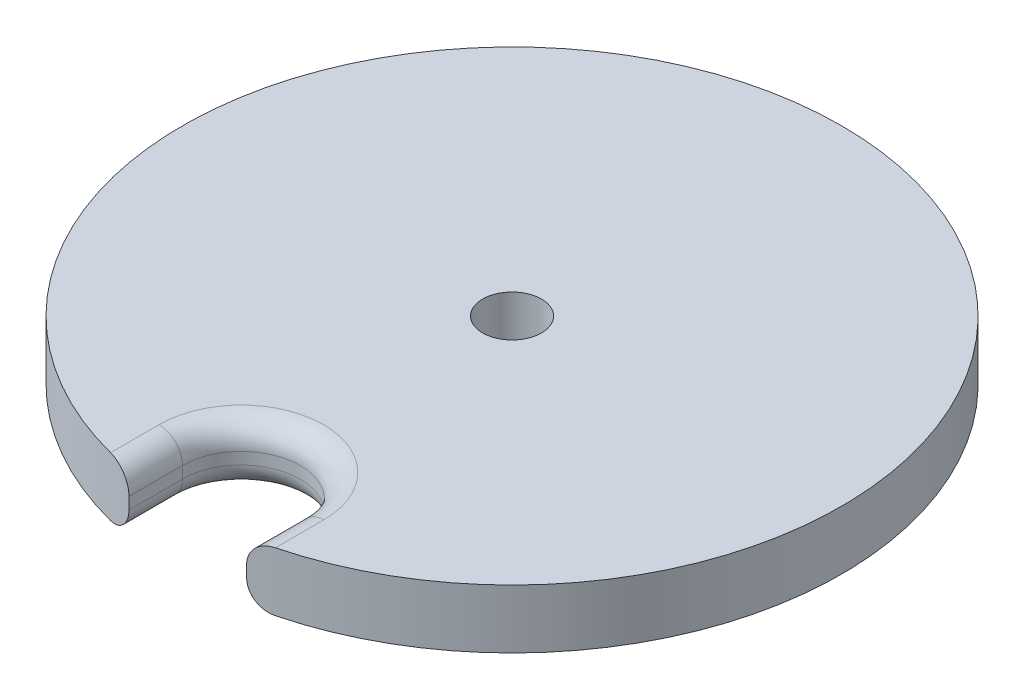
from build123d import *

# Parameters (mm, degrees)
SKETCH2_R                  = 35.56
BOSS_EXTRUDE1_DEPTH        = 6.35
SHOCK_CORD_HOLE_DEPTH      = 1
SHOCK_CORD_HOLE_DEPTH_BACK = 7.35
FILLET1_R                  = 2.54
SKETCH18_R                 = 3.175
CUT_EXTRUDE1_DEPTH         = 7.3500001


with BuildPart() as part:
    # Sketch2 → Boss-Extrude1 (new body)
    with BuildSketch(Plane(origin=(0, 0, 0), x_dir=(1, 0, 0), z_dir=(0, 1, 0))):
        Circle(SKETCH2_R)
    extrude(amount=BOSS_EXTRUDE1_DEPTH)

    # Sketch4 → Shock Cord hole (cut, two sides)
    with BuildSketch(Plane(origin=(0, 6.35, 0), x_dir=(1, 0, 0), z_dir=(0, 1, 0))) as shock_cord_hole_sk:
        with BuildLine():
            Line((6.35, -209.104630755), (6.35, -34.988442377))
            Line((6.35, -34.988442377), (6.35, -29.21))
            ThreePointArc((6.35, -29.21), (0, -22.86), (-6.35, -29.21))
            Line((-6.35, -29.21), (-6.35, -34.988442377))
            Line((-6.35, -34.988442377), (-6.35, -209.104630755))
            Line((-6.35, -209.104630755), (-6.35, -557.33700751))
            Line((-6.35, -557.33700751), (6.35, -557.33700751))
            Line((6.35, -557.33700751), (6.35, -209.104630755))
        make_face()
    extrude(amount=SHOCK_CORD_HOLE_DEPTH, mode=Mode.SUBTRACT)
    extrude(shock_cord_hole_sk.sketch, amount=-SHOCK_CORD_HOLE_DEPTH_BACK, mode=Mode.SUBTRACT)

    # Fillet1
    fillet1_edges = [part.edges().sort_by_distance(p)[0] for p in [
        (-6.35, 6.35, 32.099221189),
        (0, 6.35, 22.86),
        (6.35, 6.35, 32.099221189),
        (6.35, 0, 32.099221189),
        (0, 0, 22.86),
        (-6.35, 0, 32.099221189),
    ]]
    fillet(fillet1_edges, radius=FILLET1_R)

    # Sketch18 → Cut-Extrude1 (cut, through all)
    with BuildSketch(Plane.XZ):
        Circle(SKETCH18_R)
    extrude(amount=-CUT_EXTRUDE1_DEPTH, mode=Mode.SUBTRACT)


solid = part.part
